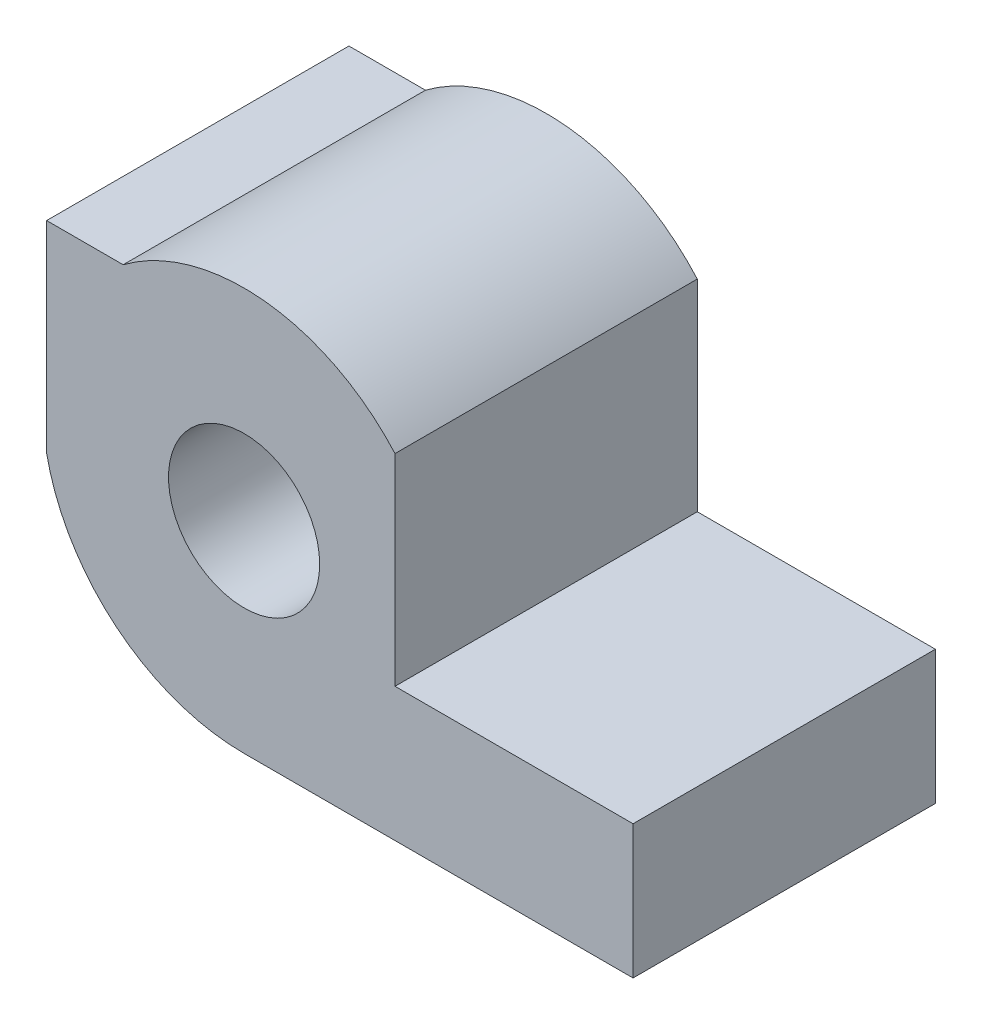
from build123d import *

# Parameters (mm, degrees)
SKETCH1_R           = 1.5
BOSS_EXTRUDE1_DEPTH = 6


with BuildPart() as part:
    # Sketch1 → Boss-Extrude1 (new body)
    with BuildSketch(Plane.XY):
        with BuildLine():
            Line((8.319591794, -4), (0.599591794, -4))
            ThreePointArc((0.599591794, -4), (-1.930230334, -3.098386677), (-3.319591794, -0.8))
            Line((-3.319591794, -0.8), (-3.319591794, 3.2))
            Line((-3.319591794, 3.2), (-1.800408206, 3.2))
            ThreePointArc((-1.800408206, 3.2), (1.004202752, 3.979483631), (3.594535859, 2.651473185))
            Line((3.594535859, 2.651473185), (3.594535859, -1.348526815))
            Line((3.594535859, -1.348526815), (8.319591794, -1.348526815))
            Line((8.319591794, -1.348526815), (8.319591794, -4))
        make_face()
        with Locations((0.599591794, 0)):
            Circle(SKETCH1_R, mode=Mode.SUBTRACT)
    extrude(amount=BOSS_EXTRUDE1_DEPTH)


solid = part.part
